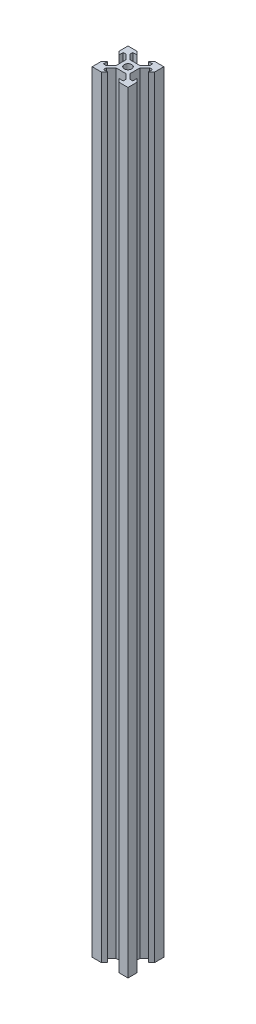
from build123d import *

# Parameters (mm, degrees)
SKETCH_1_R      = 2.1
EXTRUDE_1_DEPTH = 430


with BuildPart() as part:
    # 草图1 → 凸台-拉伸1 (new body)
    with BuildSketch(Plane(origin=(0, 0, 0), x_dir=(1, 0, 0), z_dir=(0, 1, 0))):
        Polygon((-10, 10), (-4.9, 10), (-3.1, 8.2), (-5.5, 8.2), (-5.5, 6.560660172), (-2.839339828, 3.9), (0, 3.9), (2.839339828, 3.9), (5.5, 6.560660172), (5.5, 8.2), (3.1, 8.2), (4.9, 10), (10, 10), (10, 4.9), (8.2, 3.1), (8.2, 5.5), (6.560660172, 5.5), (3.9, 2.839339828), (3.9, -2.839339828), (6.560660172, -5.5), (8.2, -5.5), (8.2, -3.1), (10, -4.9), (10, -10), (4.9, -10), (3.1, -8.2), (5.5, -8.2), (5.5, -6.560660172), (2.839339828, -3.9), (0, -3.9), (-2.839339828, -3.9), (-5.5, -6.560660172), (-5.5, -8.2), (-3.1, -8.2), (-4.9, -10), (-10, -10), (-10, -4.9), (-8.2, -3.1), (-8.2, -5.5), (-6.560660172, -5.5), (-3.9, -2.839339828), (-3.9, 2.839339828), (-6.560660172, 5.5), (-8.2, 5.5), (-8.2, 3.1), (-10, 4.9), align=None)
        Circle(SKETCH_1_R, mode=Mode.SUBTRACT)
    extrude(amount=EXTRUDE_1_DEPTH)


solid = part.part
